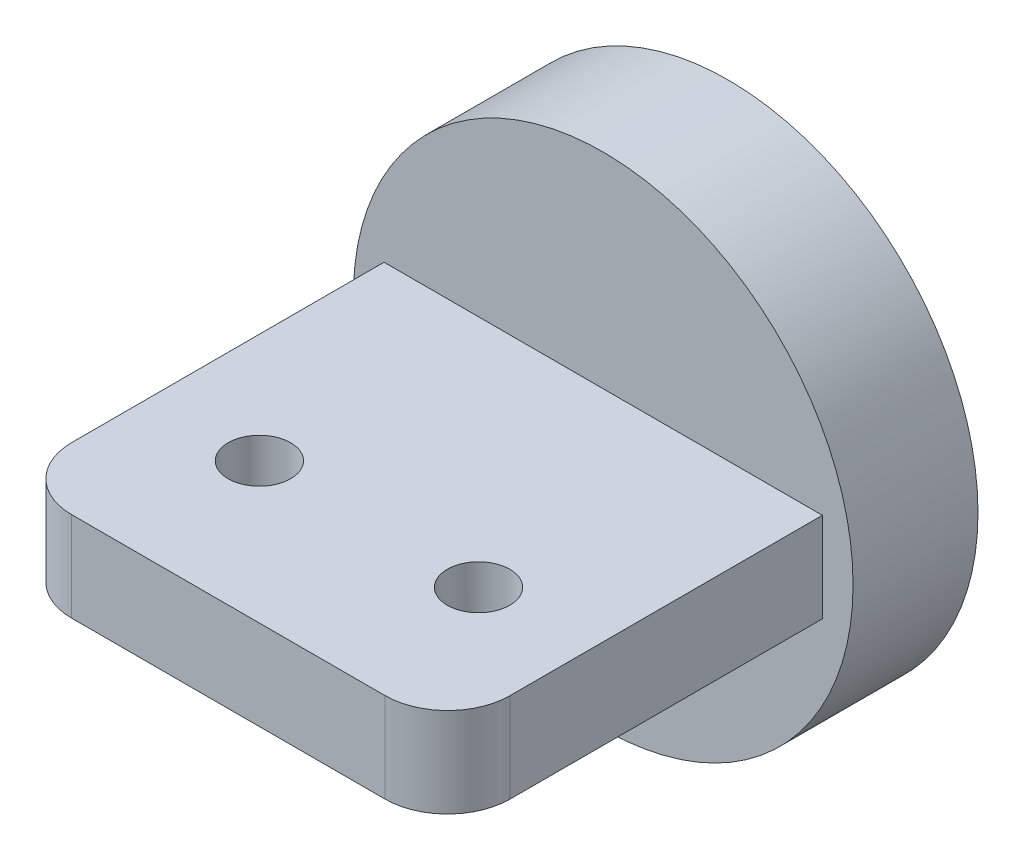
from build123d import *

# Parameters (mm, degrees)
SKETCH1_R           = 20
BOSS_EXTRUDE1_DEPTH = 10
SKETCH2_W           = 35.08265457
SKETCH2_H           = 7.175997526
BOSS_EXTRUDE2_DEPTH = 30
FILLET1_R           = 5
SKETCH3_R           = 2.5
CUT_EXTRUDE1_DEPTH  = 30
SKETCH4_R           = 10
CUT_EXTRUDE2_DEPTH  = 5


with BuildPart() as part:
    # Sketch1 → Boss-Extrude1 (new body)
    with BuildSketch(Plane.XY):
        Circle(SKETCH1_R)
    extrude(amount=BOSS_EXTRUDE1_DEPTH)

    # Sketch2 → Boss-Extrude2 (add)
    with BuildSketch(Plane.XY.offset(10)):
        Rectangle(SKETCH2_W, SKETCH2_H)
    extrude(amount=BOSS_EXTRUDE2_DEPTH)

    # Fillet1
    fillet1_edges = [part.edges().sort_by_distance(p)[0] for p in [
        (17.541327285, 0, 40),
        (-17.541327285, 0, 40),
    ]]
    fillet(fillet1_edges, radius=FILLET1_R)

    # Sketch3 → Cut-Extrude1 (cut)
    with BuildSketch(Plane(origin=(0, 3.587998763, 0), x_dir=(1, 0, 0), z_dir=(0, 1, 0))):
        with Locations((-8.770663642, -28.75)):
            Circle(SKETCH3_R)
        with Locations((8.770663642, -28.75)):
            Circle(SKETCH3_R)
    extrude(amount=-CUT_EXTRUDE1_DEPTH, mode=Mode.SUBTRACT)

    # Sketch4 → Cut-Extrude2 (cut)
    with BuildSketch(Plane(origin=(0, 0, 0), x_dir=(-1, 0, 0), z_dir=(0, 0, -1))):
        Circle(SKETCH4_R)
    extrude(amount=-CUT_EXTRUDE2_DEPTH, mode=Mode.SUBTRACT)


solid = part.part
